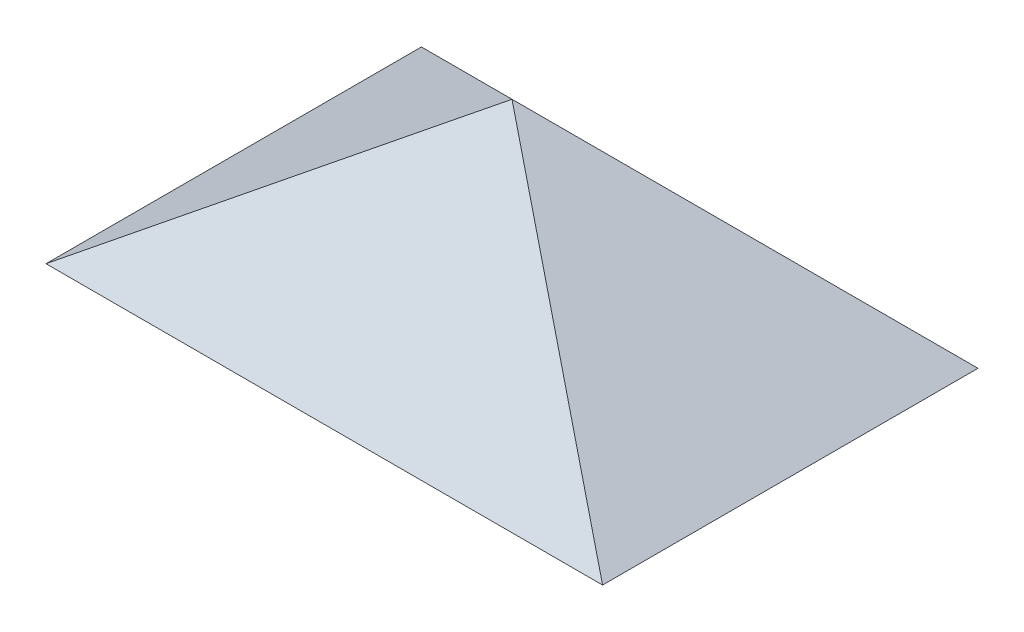
from build123d import *

# Parameters (mm, degrees)
AUFSATZ_LINEAR_START            = -68.111592
SKIZZE5_W                       = 2000
SKIZZE5_H                       = 1500
AUFSATZ_LINEAR_AUSTRAGEN1_DEPTH = 63.5
HORIZONTAL_DEPTH                = 1501
VERTIKAL_DEPTH                  = 78.537939311
VERTIKAL_DEPTH_BACK             = 78.537939311


with BuildPart() as part:
    # Skizze5 → Aufsatz-Linear austragen1 (new body)
    with BuildSketch(Plane(origin=(0, 0, 0), x_dir=(1, 0, 0), z_dir=(0, 1, 0)).offset(AUFSATZ_LINEAR_START)):
        Rectangle(SKIZZE5_W, SKIZZE5_H)
    extrude(amount=AUFSATZ_LINEAR_AUSTRAGEN1_DEPTH)

    # Skizze6 → Horizontal (cut, through all)
    with BuildSketch(Plane.XY.offset(750)):
        Polygon((0, -15.811591556), (-1000, -690.320108399), (-1000, -3.611591556), (1000, -3.611591556), (1000, -690.320108399), align=None)
    extrude(amount=-HORIZONTAL_DEPTH, mode=Mode.SUBTRACT)

    # Skizze7 → Vertikal (cut, two sides)
    with BuildSketch(Plane.ZY) as vertikal_sk:
        Polygon((0, -15.811591556), (-750, -765.811591556), (-750, -14.811591556), (750, -14.811591556), (750, -765.811591556), align=None)
    extrude(amount=VERTIKAL_DEPTH, mode=Mode.SUBTRACT)
    extrude(vertikal_sk.sketch, amount=-VERTIKAL_DEPTH_BACK, mode=Mode.SUBTRACT)


solid = part.part
